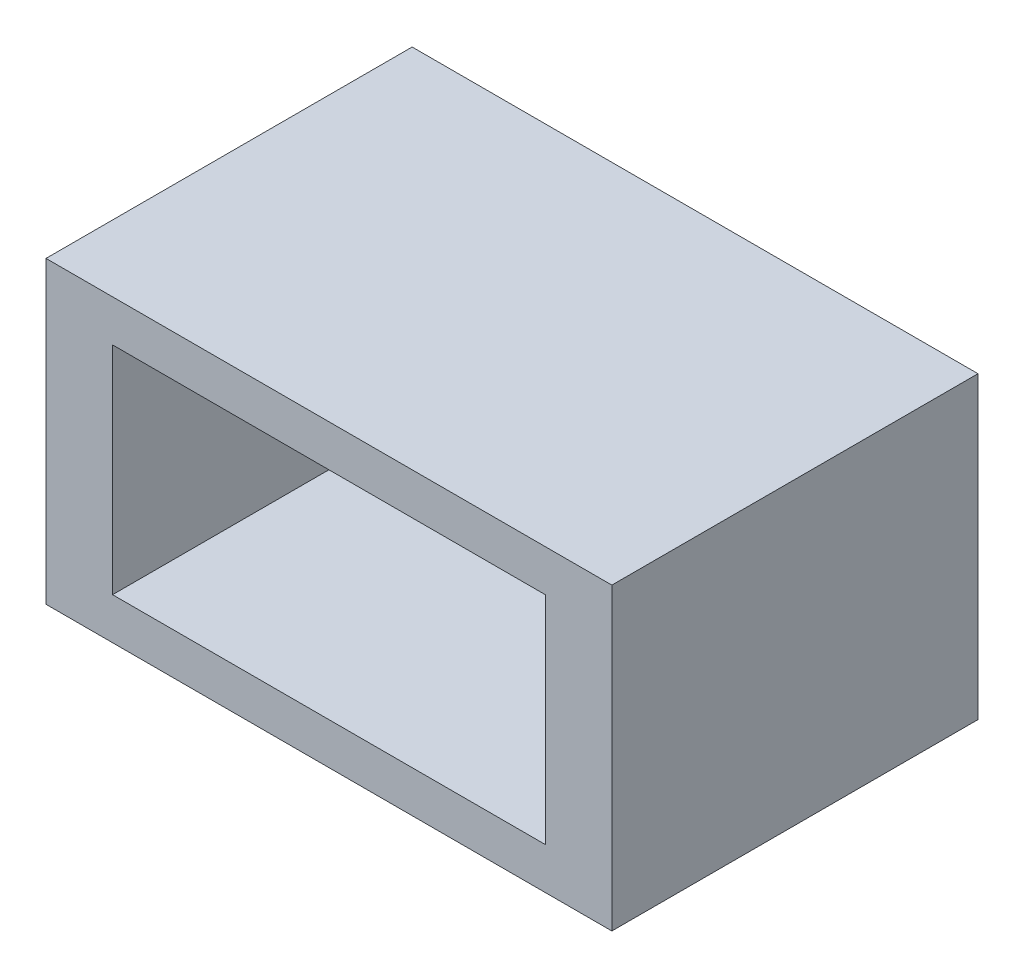
from build123d import *

# Parameters (mm, degrees)
ESQUISSE1_W             = 17
ESQUISSE1_H             = 9
BOSS_EXTRU_1_DEPTH      = 11
ESQUISSE2_W             = 13
ESQUISSE2_H             = 6.5
ENL_V_MAT_EXTRU_1_DEPTH = 11


with BuildPart() as part:
    # Esquisse1 → Boss.-Extru.1 (new body)
    with BuildSketch(Plane.XY):
        Rectangle(ESQUISSE1_W, ESQUISSE1_H)
    extrude(amount=BOSS_EXTRU_1_DEPTH)

    # Esquisse2 → Enlèv. mat.-Extru.1 (cut)
    with BuildSketch(Plane.XY.offset(11)):
        Rectangle(ESQUISSE2_W, ESQUISSE2_H)
    extrude(amount=-ENL_V_MAT_EXTRU_1_DEPTH, mode=Mode.SUBTRACT)


solid = part.part
